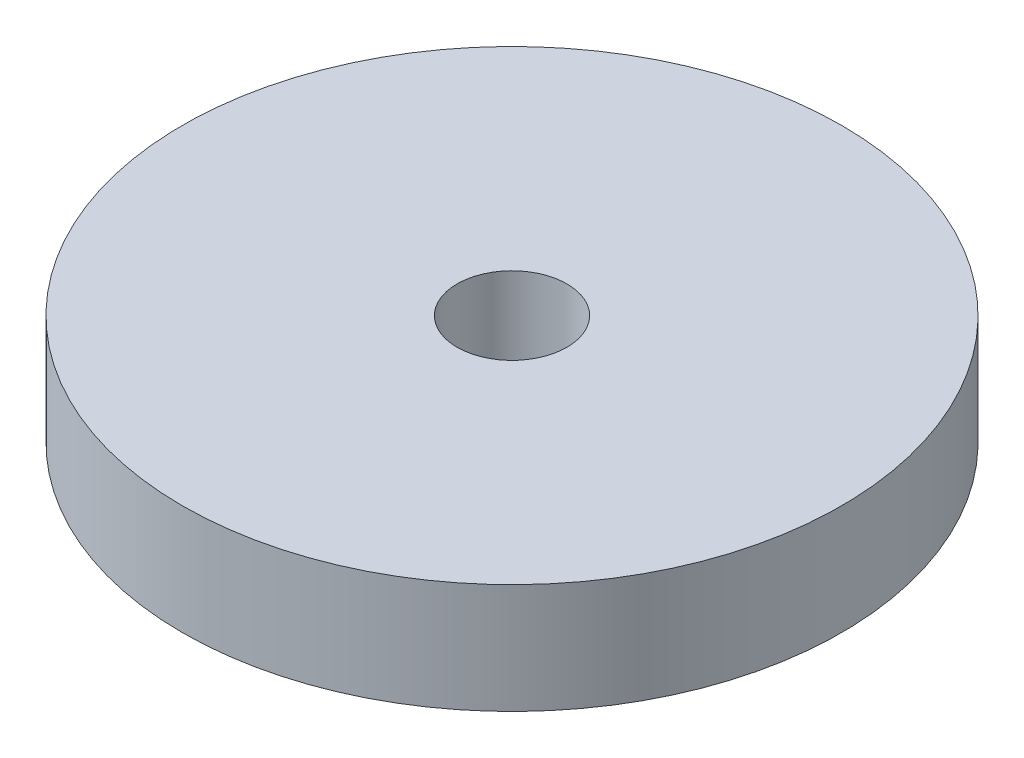
from build123d import *

# Parameters (mm, degrees)
BOSS_EXTRUDE1_DEPTH      = 25
BOSS_EXTRUDE1_DEPTH_BACK = 25
SKETCH1_R                = 150
CUT_EXTRUDE2_DEPTH       = 214.600093633
CUT_EXTRUDE2_DEPTH_BACK  = 214.600093633
SKETCH2_R                = 25


with BuildPart() as part:
    # Sketch1 → Boss-Extrude1 (new, two sides: drawn at the far end of the back side and taken through both)
    with BuildSketch(Plane(origin=(0, 0, 0), x_dir=(1, 0, 0), z_dir=(0, 1, 0)).offset(-BOSS_EXTRUDE1_DEPTH_BACK)):
        Circle(SKETCH1_R)
    extrude(amount=BOSS_EXTRUDE1_DEPTH + BOSS_EXTRUDE1_DEPTH_BACK)

    # Sketch2 → Cut-Extrude2 (cut, two sides: drawn at the far end of the back side and taken through both)
    with BuildSketch(Plane(origin=(0, 0, 0), x_dir=(1, 0, 0), z_dir=(0, 1, 0)).offset(-CUT_EXTRUDE2_DEPTH_BACK)):
        Circle(SKETCH2_R)
    extrude(amount=CUT_EXTRUDE2_DEPTH + CUT_EXTRUDE2_DEPTH_BACK, mode=Mode.SUBTRACT)


solid = part.part
